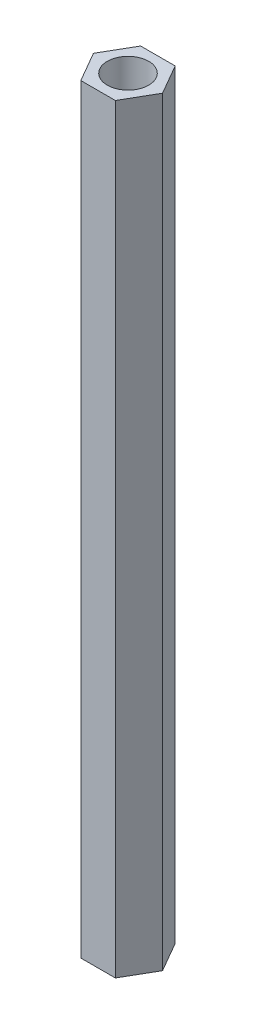
from build123d import *

# Parameters (mm, degrees)
SKETCH_1_R      = 1.5
EXTRUDE_1_DEPTH = 55


with BuildPart() as part:
    # 草图1 → 凸台-拉伸1 (new body)
    with BuildSketch(Plane(origin=(0, 0, 0), x_dir=(1, 0, 0), z_dir=(0, 1, 0))):
        Polygon((-2.5, 0), (-1.25, -2.165063509), (1.25, -2.165063509), (2.5, 0), (1.25, 2.165063509), (-1.25, 2.165063509), align=None)
        Circle(SKETCH_1_R, mode=Mode.SUBTRACT)
    extrude(amount=EXTRUDE_1_DEPTH)


solid = part.part
